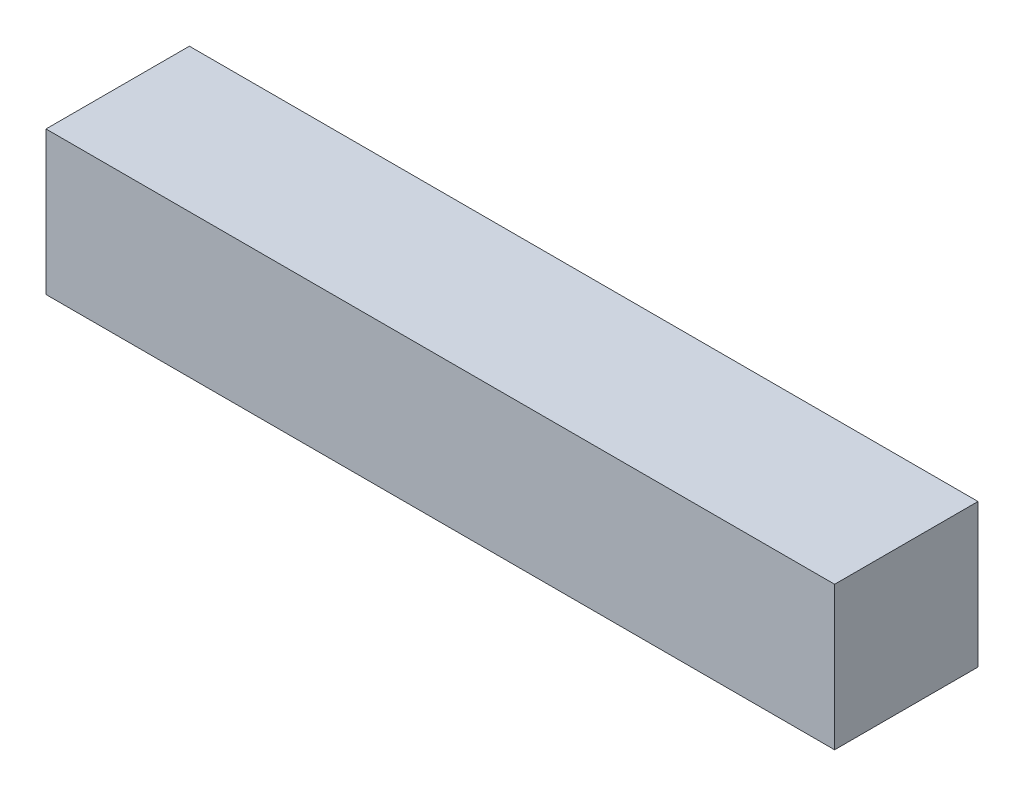
from build123d import *

# Parameters (mm, degrees)
SKETCH1_W           = 17.4625
SKETCH1_H           = 3.175
BOSS_EXTRUDE1_DEPTH = 3.175


with BuildPart() as part:
    # Sketch1 → Boss-Extrude1 (new body)
    with BuildSketch(Plane.XY):
        with Locations((8.73125, 1.5875)):
            Rectangle(SKETCH1_W, SKETCH1_H)
    extrude(amount=BOSS_EXTRUDE1_DEPTH)


solid = part.part
